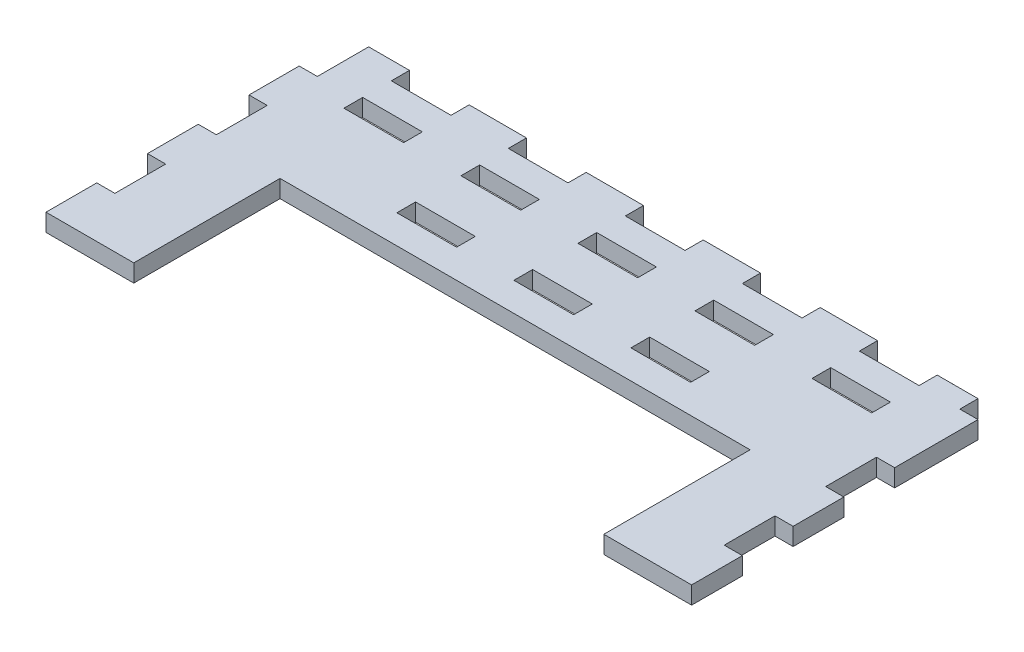
from build123d import *

# Parameters (mm, degrees)
BOSS_EXTRUDE1_DEPTH = 3
SKETCH2_W           = 3.2
SKETCH2_H           = 8.675
SKETCH2_H_2         = 8.875
SKETCH2_W_2         = 10.2
SKETCH2_H_3         = 3.2
CUT_EXTRUDE1_DEPTH  = 4


with BuildPart() as part:
    # Sketch1 → Boss-Extrude1 (new body)
    with BuildSketch(Plane(origin=(0, 0, 0), x_dir=(1, 0, 0), z_dir=(0, 1, 0))):
        Polygon((95.344434203, 0), (95.344434203, 25), (15, 25), (15, 0), (0, 0), (0, 52.05), (110.344434203, 52.05), (110.344434203, 0), align=None)
    extrude(amount=BOSS_EXTRUDE1_DEPTH)

    # Sketch2 → Cut-Extrude1 (cut, through all)
    with BuildSketch(Plane(origin=(0, 0, 0), x_dir=(1, 0, 0), z_dir=(0, 1, 0))):
        with Locations((1.5, 13.0125)):
            Rectangle(SKETCH2_W, SKETCH2_H)
        with Locations((1.5, 30.3625)):
            Rectangle(SKETCH2_W, SKETCH2_H)
        with Locations((1.5, 47.7125)):
            Rectangle(SKETCH2_W, SKETCH2_H_2)
        with Locations((35.172217102, 50.55)):
            Rectangle(SKETCH2_W_2, SKETCH2_H_3)
        with Locations((55.172217102, 31.5)):
            Rectangle(SKETCH2_W_2, SKETCH2_H_3)
        with Locations((55.172217102, 42.45)):
            Rectangle(SKETCH2_W_2, SKETCH2_H_3)
        with Locations((55.172217102, 50.55)):
            Rectangle(SKETCH2_W_2, SKETCH2_H_3)
        with Locations((15.172217102, 42.45)):
            Rectangle(SKETCH2_W_2, SKETCH2_H_3)
        with Locations((15.172217102, 50.55)):
            Rectangle(SKETCH2_W_2, SKETCH2_H_3)
        with Locations((35.172217102, 31.5)):
            Rectangle(SKETCH2_W_2, SKETCH2_H_3)
        with Locations((35.172217102, 42.45)):
            Rectangle(SKETCH2_W_2, SKETCH2_H_3)
        with Locations((108.844434203, 13.0125)):
            Rectangle(SKETCH2_W, SKETCH2_H)
        with Locations((95.172217102, 42.45)):
            Rectangle(SKETCH2_W_2, SKETCH2_H_3)
        with Locations((95.172217102, 50.55)):
            Rectangle(SKETCH2_W_2, SKETCH2_H_3)
        with Locations((108.844434203, 30.3625)):
            Rectangle(SKETCH2_W, SKETCH2_H)
        with Locations((75.172217102, 50.55)):
            Rectangle(SKETCH2_W_2, SKETCH2_H_3)
        with Locations((75.172217102, 42.45)):
            Rectangle(SKETCH2_W_2, SKETCH2_H_3)
        with Locations((75.172217102, 31.5)):
            Rectangle(SKETCH2_W_2, SKETCH2_H_3)
        with Locations((108.844434203, 50.55)):
            Rectangle(SKETCH2_W, SKETCH2_H_3)
    extrude(amount=CUT_EXTRUDE1_DEPTH, mode=Mode.SUBTRACT)


solid = part.part
